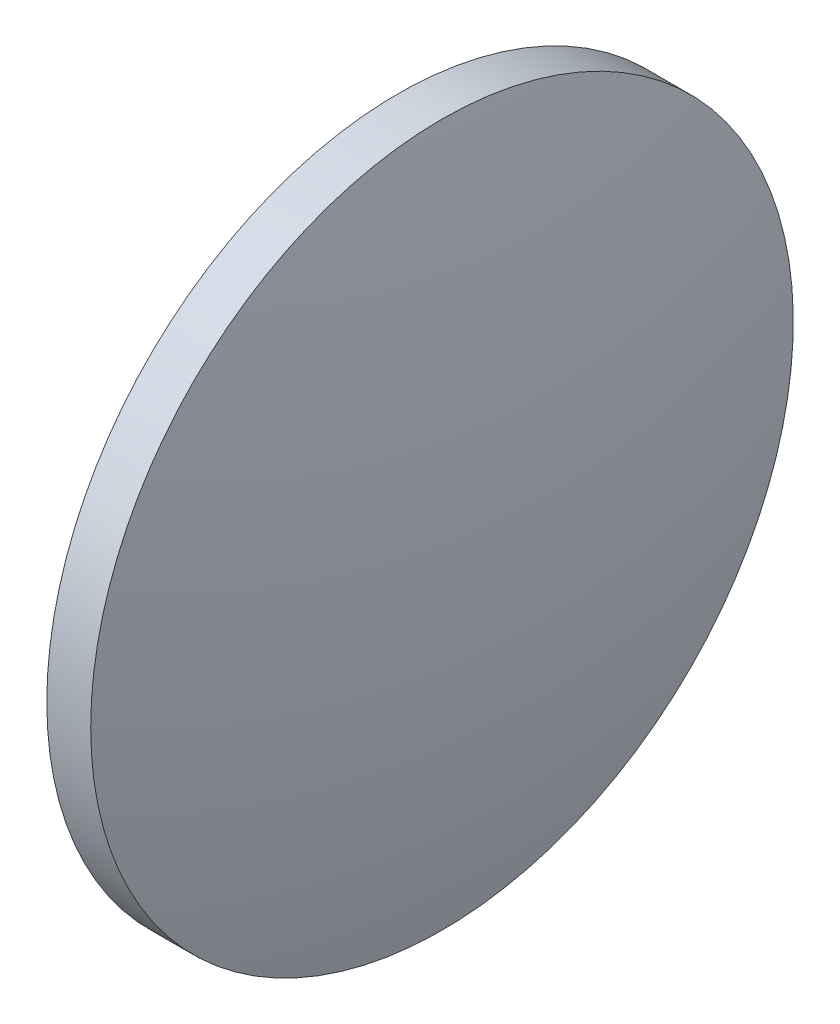
from build123d import *


with BuildPart() as part:
    # 草图1 → 旋转1 (revolve)
    with BuildSketch(Plane.XY):
        with BuildLine():
            Line((648.944760987, 6.345979496), (648.944760987, 26.345979496))
            Line((648.944760987, 26.345979496), (651.444760987, 26.345979496))
            ThreePointArc((651.444760987, 26.345979496), (653.287452334, 16.421340532), (653.904760987, 6.345979496))
            Line((653.904760987, 6.345979496), (648.944760987, 6.345979496))
        make_face()
    revolve(axis=Axis((644.250217807, 6.345979496, 0), (1, 0, 0)))


solid = part.part
